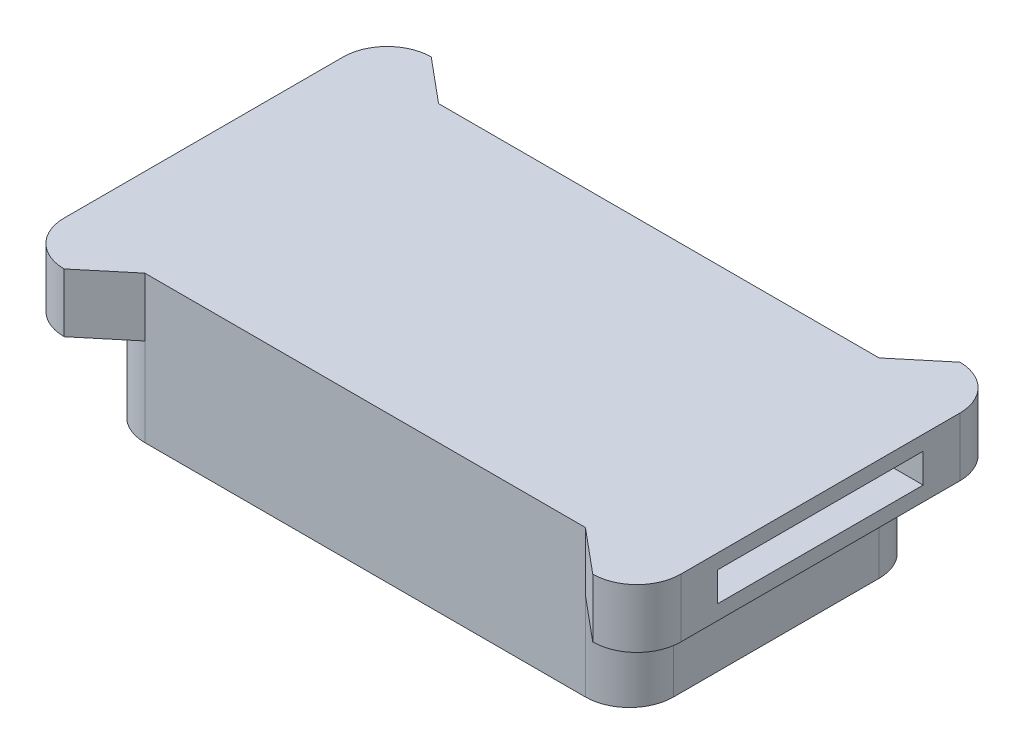
from build123d import *

# Parameters (mm, degrees)
BOSS_EXTRUDE1_DEPTH      = 2
BOSS_EXTRUDE1_DEPTH_BACK = 3
BOSS_EXTRUDE2_DEPTH      = 2
BOSS_EXTRUDE3_DEPTH      = 2
SKETCH3_W                = 7
SKETCH3_H                = 1
CUT_EXTRUDE2_DEPTH       = 1.2
SKETCH4_W                = 7
SKETCH4_H                = 1
CUT_EXTRUDE3_DEPTH       = 1.2


with BuildPart() as part:
    # Sketch2 → Boss-Extrude1 (new, two sides: drawn at the far end of the back side and taken through both)
    with BuildSketch(Plane(origin=(0, 0, 0), x_dir=(1, 0, 0), z_dir=(0, 1, 0)).offset(-BOSS_EXTRUDE1_DEPTH_BACK)):
        with BuildLine():
            Line((7.5, 5), (-7.5, 5))
            ThreePointArc((-7.5, 5), (-8.560660172, 4.560660172), (-9, 3.5))
            Line((-9, 3.5), (-9, -3.5))
            ThreePointArc((-9, -3.5), (-8.560660172, -4.560660172), (-7.5, -5))
            Line((-7.5, -5), (7.5, -5))
            ThreePointArc((7.5, -5), (8.560660172, -4.560660172), (9, -3.5))
            Line((9, -3.5), (9, 3.5))
            ThreePointArc((9, 3.5), (8.560660172, 4.560660172), (7.5, 5))
        make_face()
        with BuildLine():
            Line((-6.75, 4.25), (6.75, 4.25))
            ThreePointArc((6.75, 4.25), (7.810660172, 3.810660172), (8.25, 2.75))
            Line((8.25, 2.75), (8.25, -2.75))
            ThreePointArc((8.25, -2.75), (7.810660172, -3.810660172), (6.75, -4.25))
            Line((6.75, -4.25), (-6.75, -4.25))
            ThreePointArc((-6.75, -4.25), (-7.810660172, -3.810660172), (-8.25, -2.75))
            Line((-8.25, -2.75), (-8.25, 2.75))
            ThreePointArc((-8.25, 2.75), (-7.810660172, 3.810660172), (-6.75, 4.25))
        make_face(mode=Mode.SUBTRACT)
    extrude(amount=BOSS_EXTRUDE1_DEPTH + BOSS_EXTRUDE1_DEPTH_BACK)

    # Sketch2_3 → Boss-Extrude2 (add)
    with BuildSketch(Plane(origin=(0, 0, 0), x_dir=(1, 0, 0), z_dir=(0, 1, 0))):
        with BuildLine():
            ThreePointArc((8.25, 2.75), (7.810660172, 3.810660172), (6.75, 4.25))
            Line((6.75, 4.25), (-6.75, 4.25))
            ThreePointArc((-6.75, 4.25), (-7.810660172, 3.810660172), (-8.25, 2.75))
            Line((-8.25, 2.75), (-8.25, -2.75))
            ThreePointArc((-8.25, -2.75), (-7.810660172, -3.810660172), (-6.75, -4.25))
            Line((-6.75, -4.25), (6.75, -4.25))
            ThreePointArc((6.75, -4.25), (7.810660172, -3.810660172), (8.25, -2.75))
            Line((8.25, -2.75), (8.25, 2.75))
        make_face()
    extrude(amount=BOSS_EXTRUDE2_DEPTH)

    # Sketch2_4 → Boss-Extrude3 (add)
    with BuildSketch(Plane(origin=(0, 0, 0), x_dir=(1, 0, 0), z_dir=(0, 1, 0))):
        with BuildLine():
            Line((-7.5, 5), (-9, 6.25))
            ThreePointArc((-9, 6.25), (-10.060660172, 5.810660172), (-10.5, 4.75))
            Line((-10.5, 4.75), (-10.5, -4.75))
            ThreePointArc((-10.5, -4.75), (-10.060660172, -5.810660172), (-9, -6.25))
            Line((-9, -6.25), (-7.5, -5))
            ThreePointArc((-7.5, -5), (-8.560660172, -4.560660172), (-9, -3.5))
            Line((-9, -3.5), (-9, 3.5))
            ThreePointArc((-9, 3.5), (-8.560660172, 4.560660172), (-7.5, 5))
        make_face()
        with BuildLine():
            Line((9, 6.25), (7.5, 5))
            ThreePointArc((7.5, 5), (8.560660172, 4.560660172), (9, 3.5))
            Line((9, 3.5), (9, -3.5))
            ThreePointArc((9, -3.5), (8.560660172, -4.560660172), (7.5, -5))
            Line((7.5, -5), (9, -6.25))
            ThreePointArc((9, -6.25), (10.060660172, -5.810660172), (10.5, -4.75))
            Line((10.5, -4.75), (10.5, 4.75))
            ThreePointArc((10.5, 4.75), (10.060660172, 5.810660172), (9, 6.25))
        make_face()
    extrude(amount=BOSS_EXTRUDE3_DEPTH)

    # Sketch3 → Cut-Extrude2 (cut)
    with BuildSketch(Plane.ZY.offset(10.5)):
        with Locations((0, 1)):
            Rectangle(SKETCH3_W, SKETCH3_H)
    extrude(amount=-CUT_EXTRUDE2_DEPTH, mode=Mode.SUBTRACT)

    # Sketch4 → Cut-Extrude3 (cut)
    with BuildSketch(Plane(origin=(10.5, 0, 0), x_dir=(0, 0, -1), z_dir=(1, 0, 0))):
        with Locations((0, 1)):
            Rectangle(SKETCH4_W, SKETCH4_H)
    extrude(amount=-CUT_EXTRUDE3_DEPTH, mode=Mode.SUBTRACT)


solid = part.part
